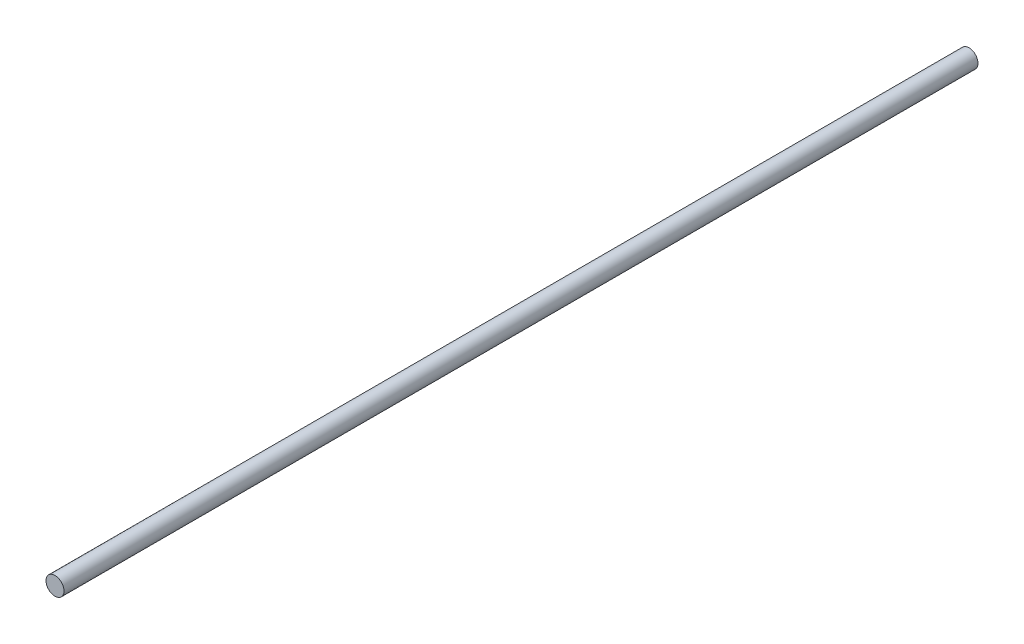
from build123d import *

# Parameters (mm, degrees)
SKETCH1_R           = 4
BOSS_EXTRUDE1_DEPTH = 406


with BuildPart() as part:
    # Sketch1 → Boss-Extrude1 (new body)
    with BuildSketch(Plane.XY):
        with Locations((6.999613824, 4.803097651)):
            Circle(SKETCH1_R)
    extrude(amount=-BOSS_EXTRUDE1_DEPTH)


solid = part.part
